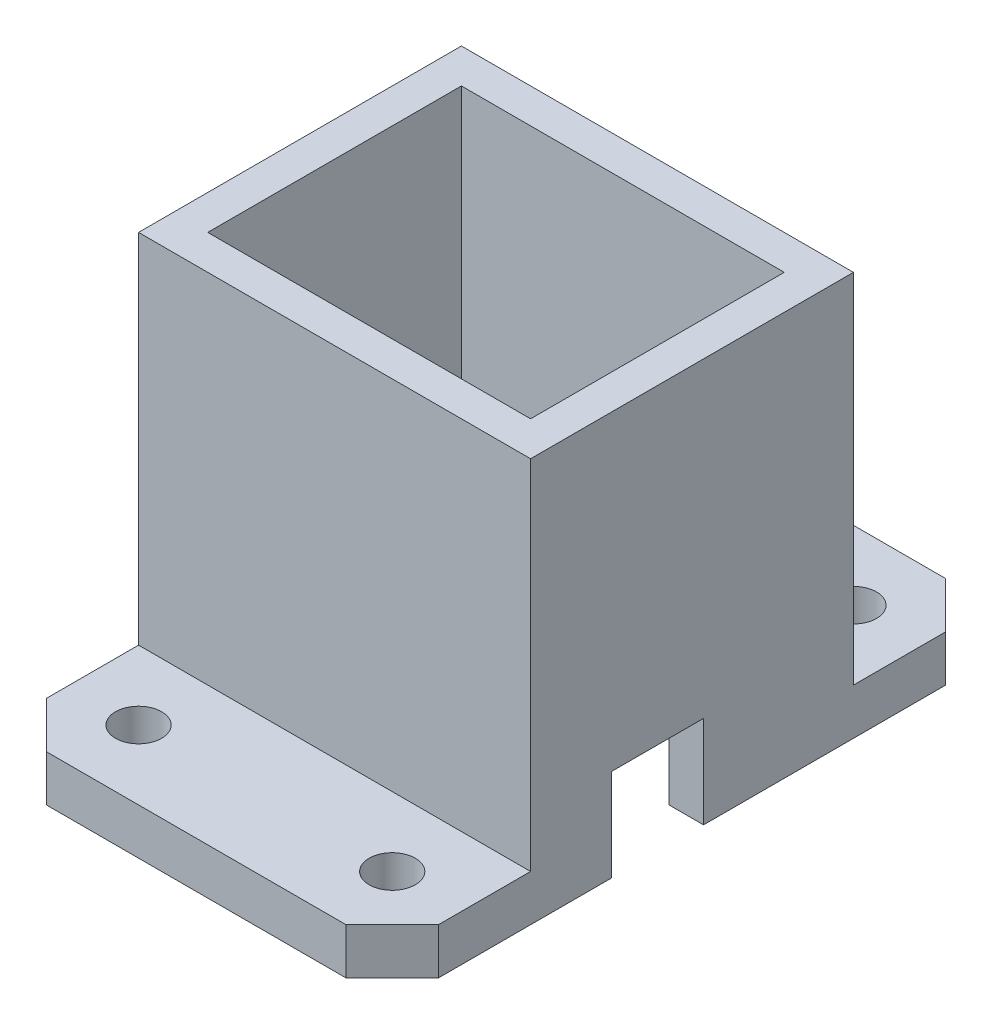
from build123d import *

# Parameters (mm, degrees)
SKETCH1_W           = 34
SKETCH1_H           = 28
SKETCH1_W_2         = 28
SKETCH1_H_2         = 22
BOSS_EXTRUDE1_DEPTH = 35
SKETCH2_W           = 8
SKETCH2_H           = 8
CUT_EXTRUDE1_DEPTH  = 35
SKETCH3_W           = 34
SKETCH3_H           = 4
BOSS_EXTRUDE2_DEPTH = 12
SKETCH4_W           = 34
SKETCH4_H           = 4
BOSS_EXTRUDE3_DEPTH = 12
CHAMFER1_SIZE       = 4
SKETCH5_R           = 2
CUT_EXTRUDE2_DEPTH  = 4


with BuildPart() as part:
    # Sketch1 → Boss-Extrude1 (new body)
    with BuildSketch(Plane(origin=(0, 0, 0), x_dir=(1, 0, 0), z_dir=(0, 1, 0))):
        Rectangle(SKETCH1_W, SKETCH1_H)
        Rectangle(SKETCH1_W_2, SKETCH1_H_2, mode=Mode.SUBTRACT)
    extrude(amount=BOSS_EXTRUDE1_DEPTH)

    # Sketch2 → Cut-Extrude1 (cut)
    with BuildSketch(Plane.ZY.offset(17)):
        with Locations((3, 4)):
            Rectangle(SKETCH2_W, SKETCH2_H)
    extrude(amount=-CUT_EXTRUDE1_DEPTH, mode=Mode.SUBTRACT)

    # Sketch3 → Boss-Extrude2 (add)
    with BuildSketch(Plane.XY.offset(14)):
        with Locations((0, 2)):
            Rectangle(SKETCH3_W, SKETCH3_H)
    extrude(amount=BOSS_EXTRUDE2_DEPTH)

    # Sketch4 → Boss-Extrude3 (add)
    with BuildSketch(Plane(origin=(0, 0, -14), x_dir=(-1, 0, 0), z_dir=(0, 0, -1))):
        with Locations((0, 2)):
            Rectangle(SKETCH4_W, SKETCH4_H)
    extrude(amount=BOSS_EXTRUDE3_DEPTH)

    # Chamfer1
    chamfer1_edges = [part.edges().sort_by_distance(p)[0] for p in [
        (-17, 2, 26),
        (17, 2, 26),
        (17, 2, -26),
        (-17, 2, -26),
    ]]
    chamfer(chamfer1_edges, length=CHAMFER1_SIZE)

    # Sketch5 → Cut-Extrude2 (cut)
    with BuildSketch(Plane(origin=(0, 4, 0), x_dir=(1, 0, 0), z_dir=(0, 1, 0))):
        with Locations((-11, -20)):
            Circle(SKETCH5_R)
        with Locations((11, -20)):
            Circle(SKETCH5_R)
        with Locations((-11, 20)):
            Circle(SKETCH5_R)
        with Locations((11, 20)):
            Circle(SKETCH5_R)
    extrude(amount=-CUT_EXTRUDE2_DEPTH, mode=Mode.SUBTRACT)


solid = part.part
